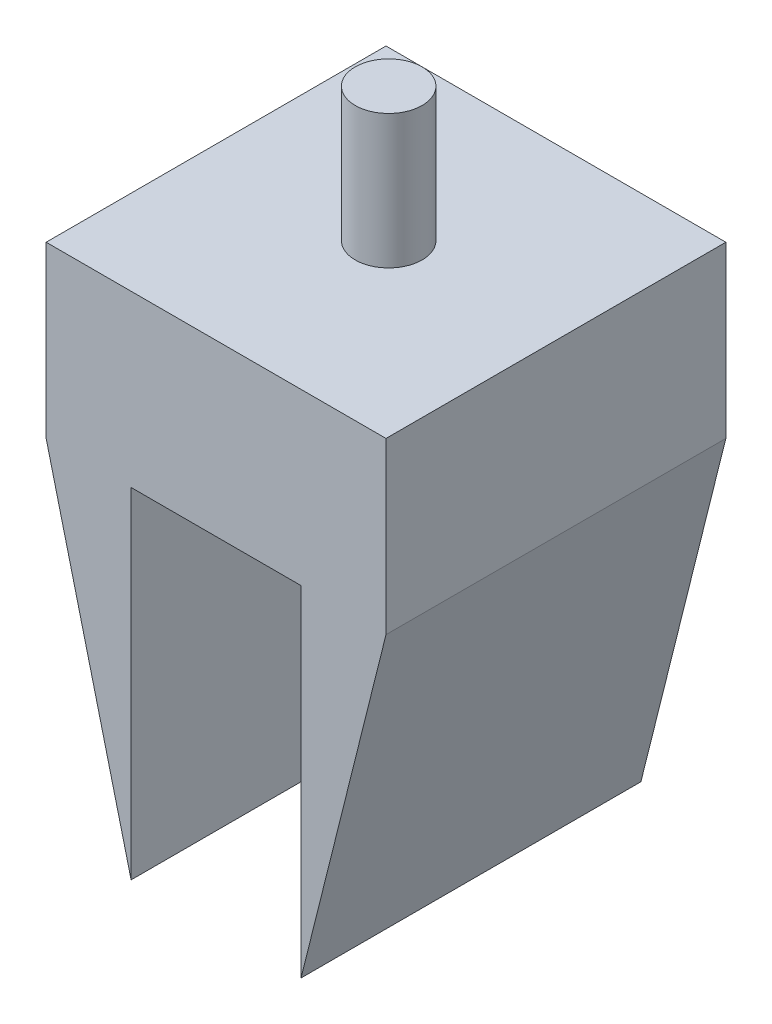
from build123d import *

# Parameters (mm, degrees)
BOSS_EXTRUDE2_DEPTH = 50.8
CUT_EXTRUDE2_DEPTH  = 63.5
CUT_EXTRUDE3_DEPTH  = 63.5
SKETCH3_R           = 5
BOSS_EXTRUDE3_DEPTH = 20


with BuildPart() as part:
    # Sketch1 → Boss-Extrude2 (new body)
    with BuildSketch(Plane.XY):
        Polygon((0, 0), (0, 76.2), (50.8, 76.2), (50.8, 0), (38.1, 0), (38.1, 50.8), (12.7, 50.8), (12.7, 0), align=None)
    extrude(amount=-BOSS_EXTRUDE2_DEPTH)

    # Sketch4 → Cut-Extrude2 (cut)
    with BuildSketch(Plane.XY):
        Polygon((0, 50.8), (12.7, 0), (0, 0), align=None)
    extrude(amount=-CUT_EXTRUDE2_DEPTH, mode=Mode.SUBTRACT)

    # Sketch5 → Cut-Extrude3 (cut)
    with BuildSketch(Plane.XY):
        Polygon((50.8, 50.8), (38.1, 0), (50.8, 0), align=None)
    extrude(amount=-CUT_EXTRUDE3_DEPTH, mode=Mode.SUBTRACT)

    # Sketch3 → Boss-Extrude3 (add)
    with BuildSketch(Plane(origin=(0, 76.2, 0), x_dir=(1, 0, 0), z_dir=(0, 1, 0))):
        with Locations((25.4, 25.8)):
            Circle(SKETCH3_R)
    extrude(amount=BOSS_EXTRUDE3_DEPTH)


solid = part.part
